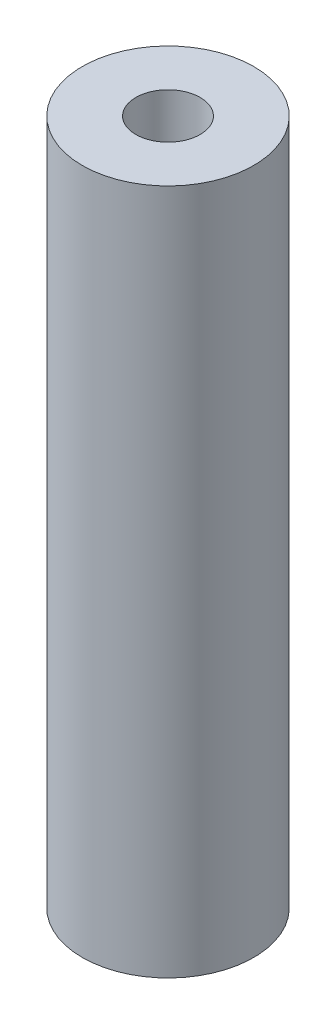
from build123d import *

# Parameters (mm, degrees)
SKETCH1_R           = 12.7
SKETCH1_R_2         = 4.7625
BOSS_EXTRUDE1_DEPTH = 101.6


with BuildPart() as part:
    # Sketch1 → Boss-Extrude1 (new body)
    with BuildSketch(Plane(origin=(0, 0, 0), x_dir=(1, 0, 0), z_dir=(0, 1, 0))):
        Circle(SKETCH1_R)
        Circle(SKETCH1_R_2, mode=Mode.SUBTRACT)
    extrude(amount=BOSS_EXTRUDE1_DEPTH)


solid = part.part
